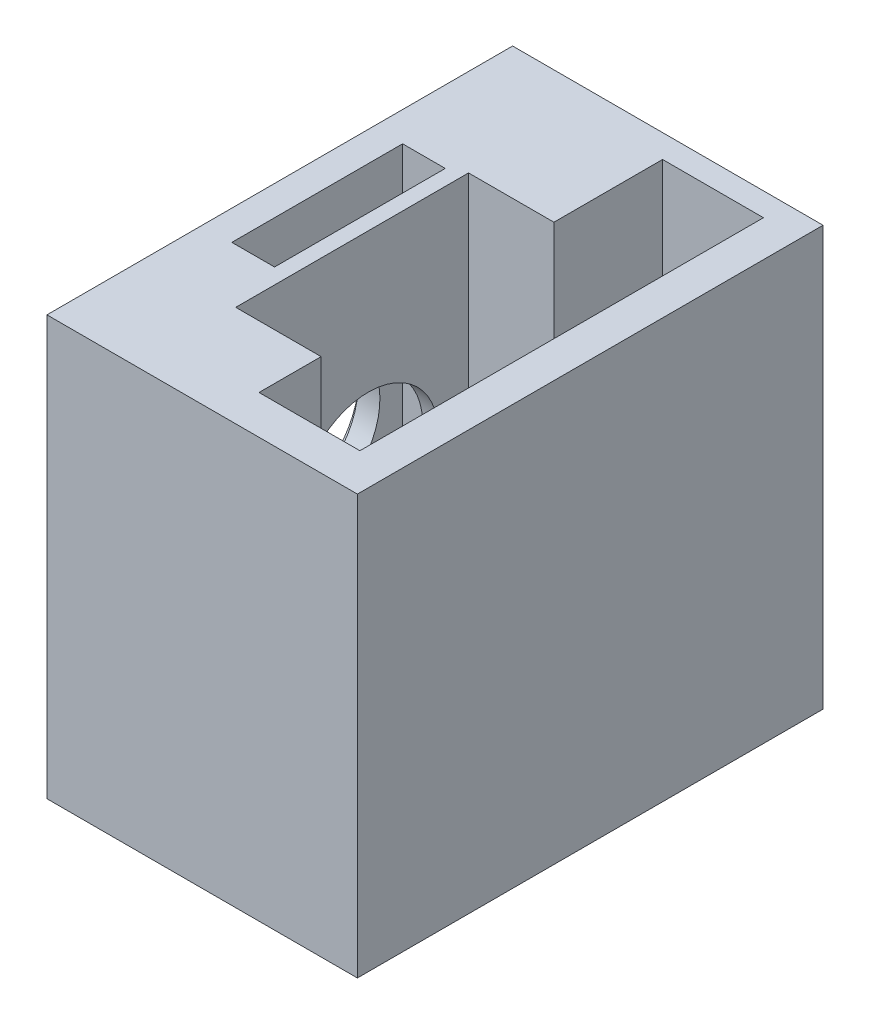
from build123d import *

# Parameters (mm, degrees)
SKETCH2_W           = 30
SKETCH2_H           = 27
BOSS_EXTRUDE1_DEPTH = 20
SKETCH6_W           = 6.5
SKETCH6_H           = 26
CUT_EXTRUDE4_DEPTH  = 26
SKETCH9_W           = 5.5
SKETCH9_H           = 15
CUT_EXTRUDE5_DEPTH  = 21
SKETCH11_R          = 5
CUT_EXTRUDE8_DEPTH  = 0.5
SKETCH12_W          = 2.75
SKETCH12_H          = 11
CUT_EXTRUDE12_DEPTH = 17.5
SKETCH15_R          = 4.5
CUT_EXTRUDE13_DEPTH = 6


with BuildPart() as part:
    # Sketch2 → Boss-Extrude1 (new body)
    with BuildSketch(Plane(origin=(0, 0, 0), x_dir=(0, 0, -1), z_dir=(1, 0, 0))):
        with Locations((15, 13.5)):
            Rectangle(SKETCH2_W, SKETCH2_H)
    extrude(amount=BOSS_EXTRUDE1_DEPTH)

    # Sketch6 → Cut-Extrude4 (cut)
    with BuildSketch(Plane(origin=(2.296116437, 27, -0.293484995), x_dir=(1, 0, 0), z_dir=(0, 1, 0))):
        with Locations((12.115844825, 15.206515005)):
            Rectangle(SKETCH6_W, SKETCH6_H)
    extrude(amount=-CUT_EXTRUDE4_DEPTH, mode=Mode.SUBTRACT)

    # Sketch9 → Cut-Extrude5 (cut)
    with BuildSketch(Plane(origin=(0, 27, 0), x_dir=(1, 0, 0), z_dir=(0, 1, 0))):
        with Locations((8.411961261, 14)):
            Rectangle(SKETCH9_W, SKETCH9_H)
    extrude(amount=-CUT_EXTRUDE5_DEPTH, mode=Mode.SUBTRACT)

    # Sketch11 → Cut-Extrude8 (cut)
    with BuildSketch(Plane.ZY):
        with Locations((-15.1, 13.5)):
            Circle(SKETCH11_R)
    extrude(amount=-CUT_EXTRUDE8_DEPTH, mode=Mode.SUBTRACT)

    # Sketch12 → Cut-Extrude12 (cut)
    with BuildSketch(Plane(origin=(0, 27, 0), x_dir=(1, 0, 0), z_dir=(0, 1, 0))):
        with Locations((3.286961261, 15.5)):
            Rectangle(SKETCH12_W, SKETCH12_H)
    extrude(amount=-CUT_EXTRUDE12_DEPTH, mode=Mode.SUBTRACT)

    # Sketch15 → Cut-Extrude13 (cut)
    with BuildSketch(Plane.ZY.offset(-0.5)):
        with Locations((-15.04, 13.5)):
            Circle(SKETCH15_R)
    extrude(amount=-CUT_EXTRUDE13_DEPTH, mode=Mode.SUBTRACT)


solid = part.part
